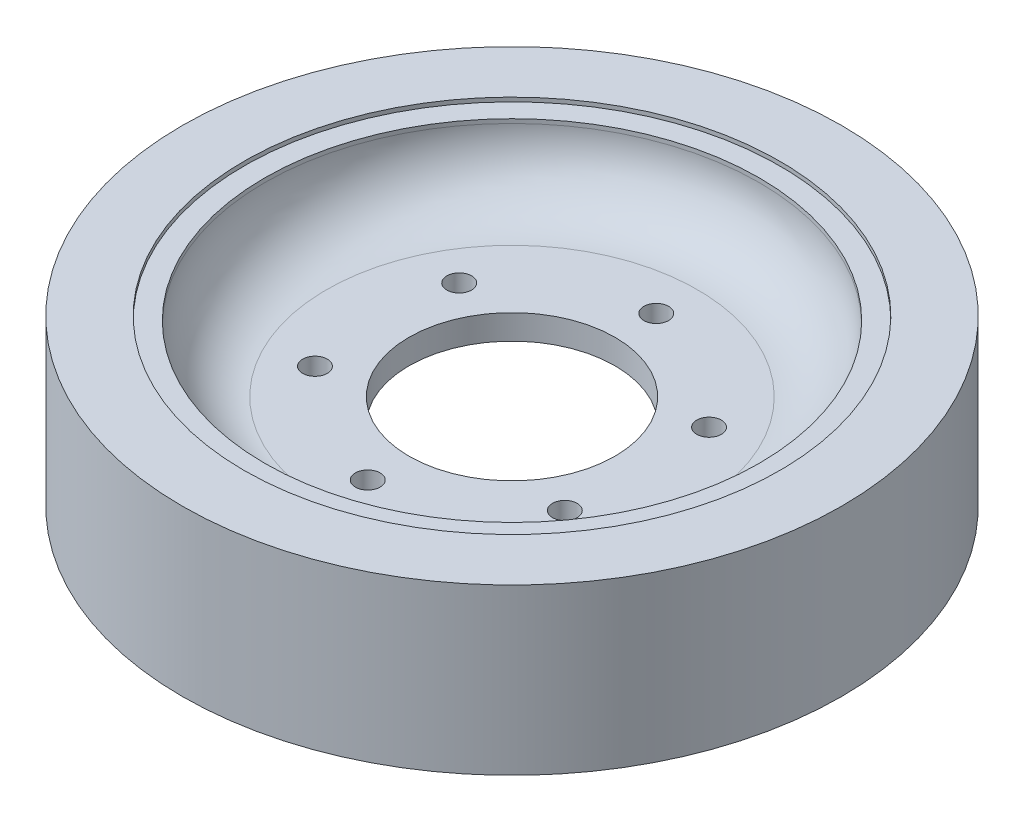
from build123d import *

# Parameters (mm, degrees)
SKETCH1_R           = 80
BOSS_EXTRUDE1_DEPTH = 40
SKETCH2_R           = 60
CUT_EXTRUDE1_DEPTH  = 17
SKETCH3_R           = 25
CUT_EXTRUDE2_DEPTH  = 24
SKETCH4_R           = 3
CUT_EXTRUDE3_DEPTH  = 24
SKETCH6_R           = 60
CUT_EXTRUDE4_DEPTH  = 17
SKETCH7_R           = 65
CUT_EXTRUDE5_DEPTH  = 1
SKETCH8_R           = 65
CUT_EXTRUDE6_DEPTH  = 1
FILLET1_R           = 15
FILLET2_R           = 15


with BuildPart() as part:
    # Sketch1 → Boss-Extrude1 (new body)
    with BuildSketch(Plane(origin=(0, 0, 0), x_dir=(1, 0, 0), z_dir=(0, 1, 0))):
        Circle(SKETCH1_R)
    extrude(amount=BOSS_EXTRUDE1_DEPTH)

    # Sketch2 → Cut-Extrude1 (cut)
    with BuildSketch(Plane(origin=(0, 40, 0), x_dir=(1, 0, 0), z_dir=(0, 1, 0))):
        Circle(SKETCH2_R)
    extrude(amount=-CUT_EXTRUDE1_DEPTH, mode=Mode.SUBTRACT)

    # Sketch3 → Cut-Extrude2 (cut, through all)
    with BuildSketch(Plane(origin=(0, 23, 0), x_dir=(1, 0, 0), z_dir=(0, 1, 0))):
        Circle(SKETCH3_R)
    extrude(amount=-CUT_EXTRUDE2_DEPTH, mode=Mode.SUBTRACT)

    # Sketch4 → Cut-Extrude3 (cut, through all)
    with BuildSketch(Plane(origin=(0, 23, 0), x_dir=(1, 0, 0), z_dir=(0, 1, 0))):
        with Locations((0, 35)):
            Circle(SKETCH4_R)
        with Locations((30.310889132, 17.5)):
            Circle(SKETCH4_R)
        with Locations((30.310889132, -17.5)):
            Circle(SKETCH4_R)
        with Locations((0, -35)):
            Circle(SKETCH4_R)
        with Locations((-30.310889132, -17.5)):
            Circle(SKETCH4_R)
        with Locations((-30.310889132, 17.5)):
            Circle(SKETCH4_R)
    extrude(amount=-CUT_EXTRUDE3_DEPTH, mode=Mode.SUBTRACT)

    # Sketch6 → Cut-Extrude4 (cut)
    with BuildSketch(Plane.XZ):
        Circle(SKETCH6_R)
    extrude(amount=-CUT_EXTRUDE4_DEPTH, mode=Mode.SUBTRACT)

    # Sketch7 → Cut-Extrude5 (cut)
    with BuildSketch(Plane.XZ):
        Circle(SKETCH7_R)
    extrude(amount=-CUT_EXTRUDE5_DEPTH, mode=Mode.SUBTRACT)

    # Sketch8 → Cut-Extrude6 (cut)
    with BuildSketch(Plane(origin=(0, 40, 0), x_dir=(1, 0, 0), z_dir=(0, 1, 0))):
        Circle(SKETCH8_R)
    extrude(amount=-CUT_EXTRUDE6_DEPTH, mode=Mode.SUBTRACT)

    # Fillet1
    fillet1_edges = [part.edges().sort_by_distance(p)[0] for p in [
        (-60, 23, 0),
    ]]
    fillet(fillet1_edges, radius=FILLET1_R)

    # Fillet2
    fillet2_edges = [part.edges().sort_by_distance(p)[0] for p in [
        (-60, 17, 0),
    ]]
    fillet(fillet2_edges, radius=FILLET2_R)


solid = part.part
